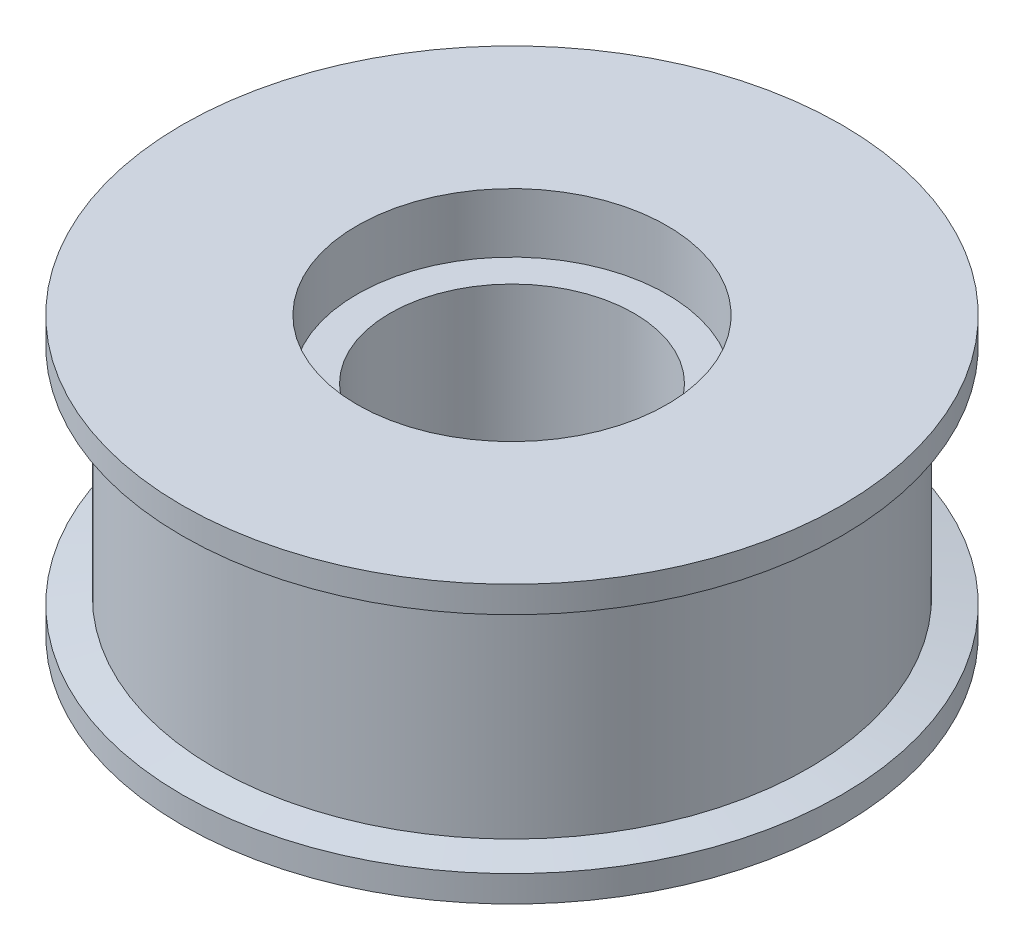
from build123d import *


with BuildPart() as part:
    # 草图1 → 旋转1 (revolve)
    with BuildSketch(Plane.XY):
        Polygon((-23.5, -14), (-23.5, -23), (-50, -23), (-50, -19), (-45, -18), (-45, 14), (-50, 15), (-50, 19), (-23.5, 19), (-23.5, 10), (-18.5, 10), (-18.5, -14), align=None)
    revolve(axis=Axis((0, 49.726947906, 0), (0, -1, 0)))


solid = part.part
